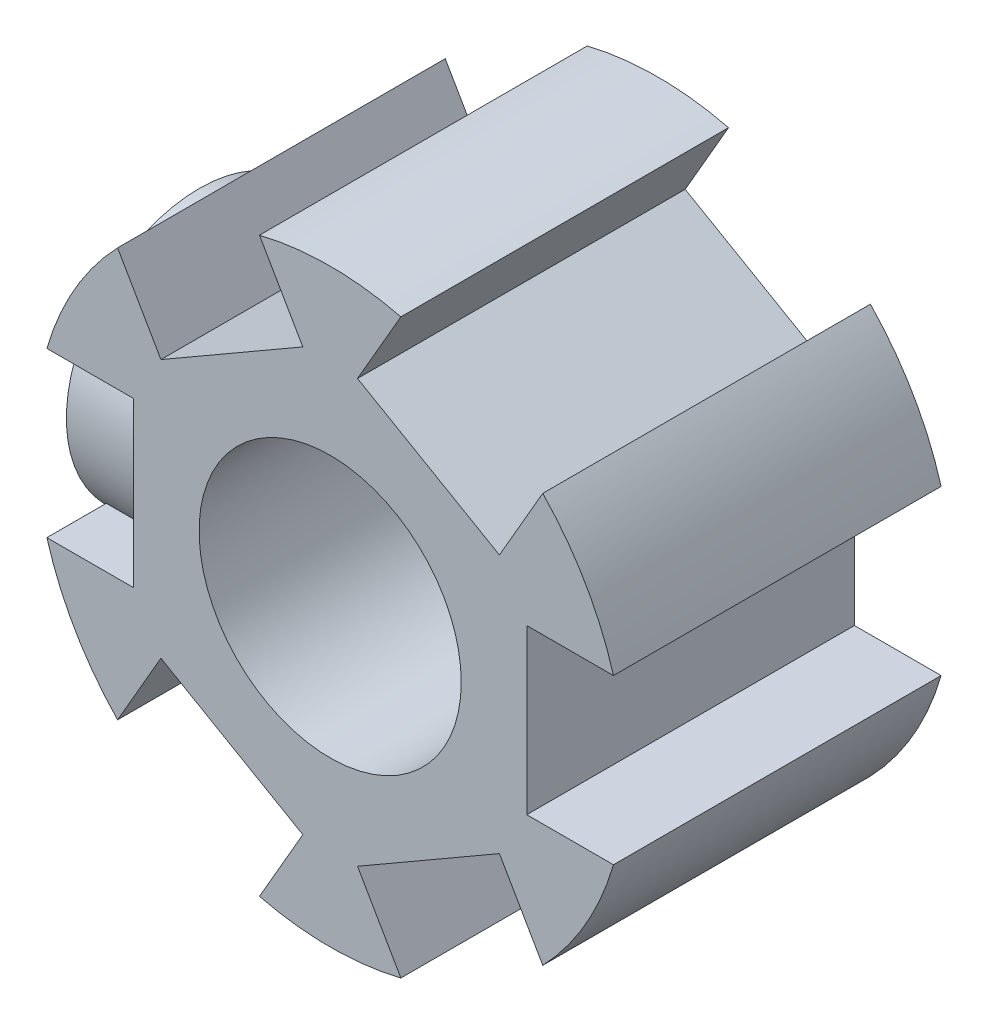
from build123d import *

# Parameters (mm, degrees)
SKETCH1_R           = 9
SKETCH1_R_2         = 4
BOSS_EXTRUDE1_DEPTH = 5
SKETCH2_W           = 5
SKETCH2_H           = 10
CUT_EXTRUDE3_DEPTH  = 3
CIRPATTERN1_COUNT   = 6
SKETCH3_R           = 4.05
BOSS_EXTRUDE2_DEPTH = 3


with BuildPart() as part:
    # Sketch1 → Boss-Extrude1 (new, symmetric)
    with BuildSketch(Plane.XY):
        Circle(SKETCH1_R)
        Circle(SKETCH1_R_2, mode=Mode.SUBTRACT)
    extrude(amount=BOSS_EXTRUDE1_DEPTH, both=True)

    # Sketch2 → Cut-Extrude3 (cut)
    with BuildSketch(Plane(origin=(-9, -17.193061184, 0), x_dir=(0, -1, 0), z_dir=(1, 0, 0))):
        with Locations((-17.193061184, 0)):
            Rectangle(SKETCH2_W, SKETCH2_H)
    cut_extrude3 = extrude(amount=CUT_EXTRUDE3_DEPTH, mode=Mode.SUBTRACT)

    # CirPattern1: Cut-Extrude3 ×6 about axis
    cirpattern1_axis = Axis((0, 0, 5), (0, 0, 1))
    for i in range(1, CIRPATTERN1_COUNT):
        add(cut_extrude3.rotate(cirpattern1_axis, i * 360 / CIRPATTERN1_COUNT), mode=Mode.SUBTRACT)

    # Sketch3 → Boss-Extrude2 (add)
    with BuildSketch(Plane(origin=(-6, 0, 0), x_dir=(0, -1, 0), z_dir=(-1, 0, 0))):
        Circle(SKETCH3_R)
    extrude(amount=BOSS_EXTRUDE2_DEPTH)


solid = part.part
